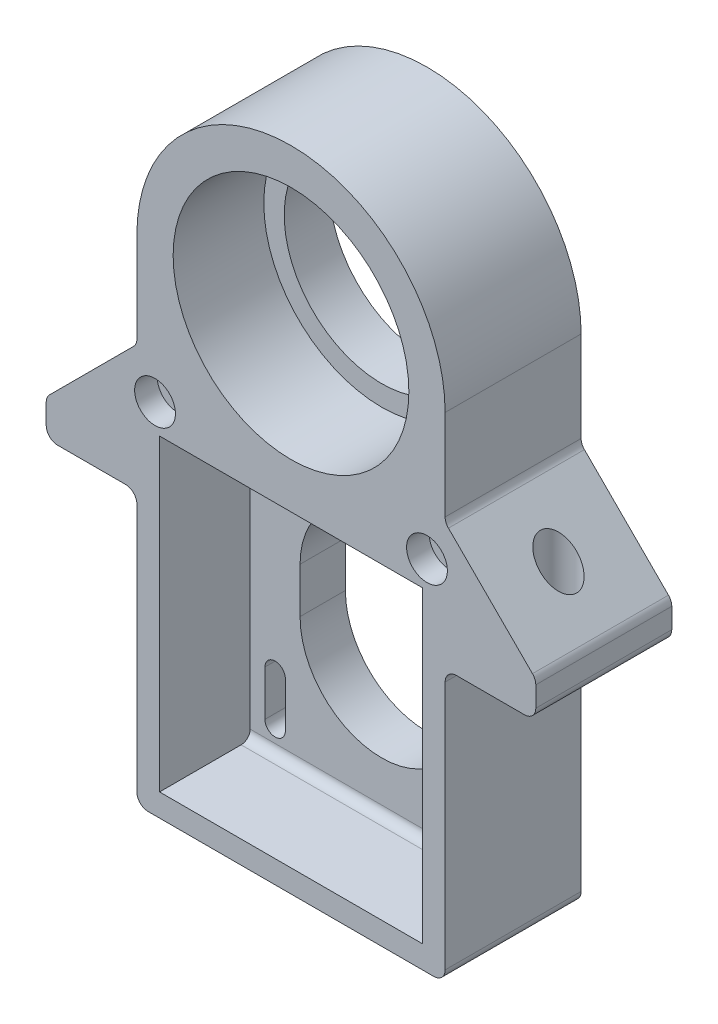
from build123d import *

# Parameters (mm, degrees)
ESQUISSE1_R             = 26
ESQUISSE1_W             = 58
ESQUISSE1_H             = 68
BOSS_EXTRU_1_DEPTH      = 20
BOSS_EXTRU_2_START      = -10
ESQUISSE1_4_R           = 21.5
BOSS_EXTRU_2_DEPTH      = 10
ESQUISSE2_R             = 4
ENL_V_MAT_EXTRU_2_DEPTH = 102.019800039
CONG_1_R                = 2.5
ESQUISSE3_R             = 2.5
ENL_V_MAT_EXTRU_3_DEPTH = 126.287668986
ESQUISSE3_3_R           = 4.5
ESQUISSE3_3_R_2         = 2.5
ENL_V_MAT_EXTRU_4_DEPTH = 5
CONG_3_R                = 2


with BuildPart() as part:
    # Esquisse1 → Boss.-Extru.1 (new body)
    with BuildSketch(Plane.XY):
        with BuildLine():
            Line((-34, 0), (-34, -21))
            Line((-34, -21), (-54, -41))
            Line((-54, -41), (-54, -49))
            Line((-54, -49), (-34, -49))
            Line((-34, -49), (-34, -109))
            Line((-34, -109), (34, -109))
            Line((34, -109), (34, -49))
            Line((34, -49), (54, -49))
            Line((54, -49), (54, -41))
            Line((54, -41), (34, -21))
            Line((34, -21), (34, 0))
            ThreePointArc((34, 0), (0, 34), (-34, 0))
        make_face()
        Circle(ESQUISSE1_R, mode=Mode.SUBTRACT)
        with Locations((0, -70)):
            Rectangle(ESQUISSE1_W, ESQUISSE1_H, mode=Mode.SUBTRACT)
    extrude(amount=BOSS_EXTRU_1_DEPTH)

    # Esquisse1_4 → Boss.-Extru.2 (add)
    with BuildSketch(Plane.XY.offset(BOSS_EXTRU_2_START)):
        with BuildLine():
            Line((-34, 0), (-34, -21))
            Line((-34, -21), (-54, -41))
            Line((-54, -41), (-54, -49))
            Line((-54, -49), (-34, -49))
            Line((-34, -49), (-34, -109))
            Line((-34, -109), (34, -109))
            Line((34, -109), (34, -49))
            Line((34, -49), (54, -49))
            Line((54, -49), (54, -41))
            Line((54, -41), (34, -21))
            Line((34, -21), (34, 0))
            ThreePointArc((34, 0), (0, 34), (-34, 0))
        make_face()
        Circle(ESQUISSE1_4_R, mode=Mode.SUBTRACT)
        with BuildLine():
            Line((-21.25, -41.5), (-21.25, -51.5))
            ThreePointArc((-21.25, -51.5), (-23.5, -53.75), (-25.75, -51.5))
            Line((-25.75, -51.5), (-25.75, -41.5))
            ThreePointArc((-25.75, -41.5), (-23.5, -39.25), (-21.25, -41.5))
        make_face(mode=Mode.SUBTRACT)
        with BuildLine():
            ThreePointArc((-25.75, -88.5), (-23.5, -86.25), (-21.25, -88.5))
            Line((-21.25, -88.5), (-21.25, -98.5))
            ThreePointArc((-21.25, -98.5), (-23.5, -100.75), (-25.75, -98.5))
            Line((-25.75, -98.5), (-25.75, -88.5))
        make_face(mode=Mode.SUBTRACT)
        with BuildLine():
            ThreePointArc((25.75, -98.5), (23.5, -100.75), (21.25, -98.5))
            Line((21.25, -98.5), (21.25, -88.5))
            ThreePointArc((21.25, -88.5), (23.5, -86.25), (25.75, -88.5))
            Line((25.75, -88.5), (25.75, -98.5))
        make_face(mode=Mode.SUBTRACT)
        with BuildLine():
            ThreePointArc((25.75, -51.5), (23.5, -53.75), (21.25, -51.5))
            Line((21.25, -51.5), (21.25, -41.5))
            ThreePointArc((21.25, -41.5), (23.5, -39.25), (25.75, -41.5))
            Line((25.75, -41.5), (25.75, -51.5))
        make_face(mode=Mode.SUBTRACT)
        with BuildLine():
            ThreePointArc((18, -75), (0, -93), (-18, -75))
            Line((-18, -75), (-18, -65))
            ThreePointArc((-18, -65), (0, -47), (18, -65))
            Line((18, -65), (18, -75))
        make_face(mode=Mode.SUBTRACT)
    extrude(amount=BOSS_EXTRU_2_DEPTH)

    # Esquisse2 → Enl_v. mat.-Extru.2 (cut, through all)
    with BuildSketch(Plane.XZ.offset(49)):
        with Locations((44, 5)):
            Circle(ESQUISSE2_R)
        with Locations((-44, 5)):
            Circle(ESQUISSE2_R)
    extrude(amount=-ENL_V_MAT_EXTRU_2_DEPTH, mode=Mode.SUBTRACT)

    # Cong_1
    cong_1_edges = [part.edges().sort_by_distance(p)[0] for p in [
        (34, -21, 5),
        (-34, -21, 5),
        (-54, -41, 5),
        (54, -49, 5),
        (54, -41, 5),
        (-54, -49, 5),
        (-34, -49, 5),
        (-34, -109, 5),
        (34, -109, 5),
        (34, -49, 5),
    ]]
    fillet(cong_1_edges, radius=CONG_1_R)

    # Esquisse3 → Enl_v. mat.-Extru.3 (cut, through all)
    with BuildSketch(Plane.XY.offset(20)):
        with Locations((-30, -30)):
            Circle(ESQUISSE3_R)
        with Locations((30, -30)):
            Circle(ESQUISSE3_R)
    extrude(amount=-ENL_V_MAT_EXTRU_3_DEPTH, mode=Mode.SUBTRACT)

    # Esquisse3_3 → Enl_v. mat.-Extru.4 (cut)
    # profile 1 of 2: a face of its own
    with BuildSketch(Plane.XY.offset(20)):
        with Locations((-30, -30)):
            Circle(ESQUISSE3_3_R)
        with Locations((-30, -30)):
            Circle(ESQUISSE3_3_R_2, mode=Mode.SUBTRACT)
    # profile 2 of 2: a face of its own
    with BuildSketch(Plane.XY.offset(20)):
        with Locations((30, -30)):
            Circle(ESQUISSE3_3_R)
        with Locations((30, -30)):
            Circle(ESQUISSE3_3_R_2, mode=Mode.SUBTRACT)
    extrude(amount=-ENL_V_MAT_EXTRU_4_DEPTH, mode=Mode.SUBTRACT)

    # Cong_3
    cong_3_edges = [part.edges().sort_by_distance(p)[0] for p in [
        (0, -104, 0),
        (0, -36, 0),
    ]]
    fillet(cong_3_edges, radius=CONG_3_R)


solid = part.part
